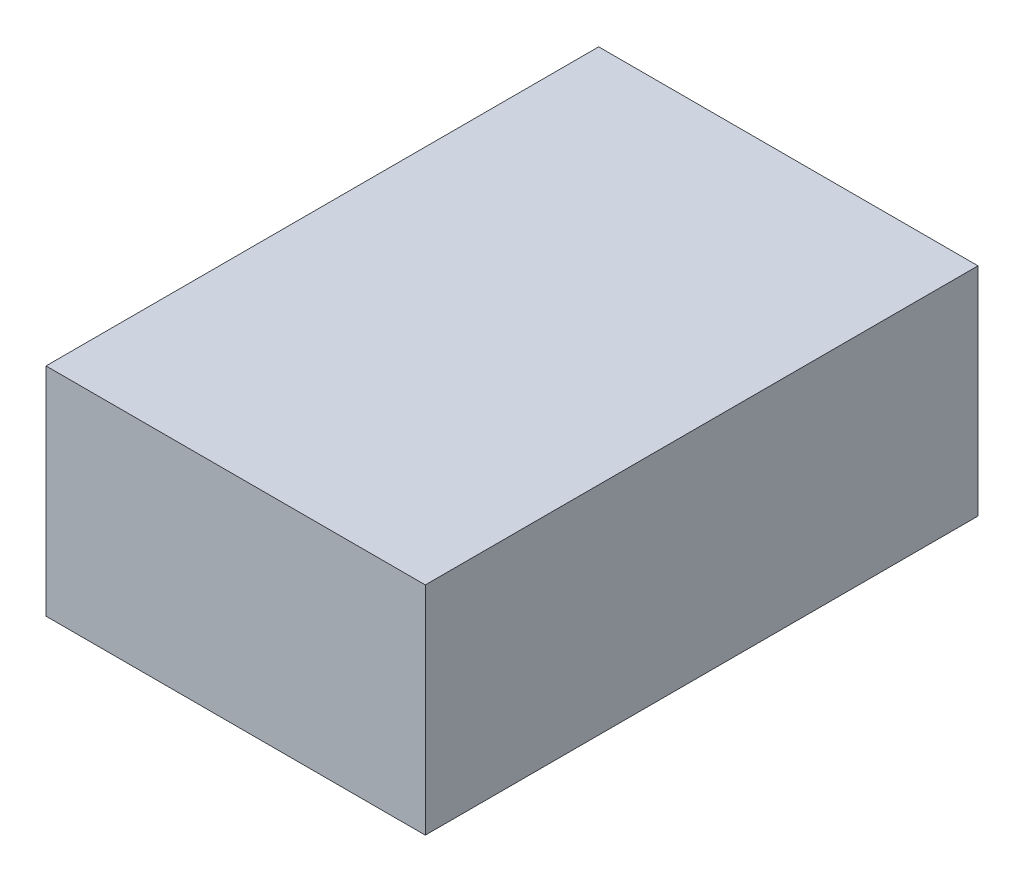
from build123d import *

# Parameters (mm, degrees)
SKETCH1_W           = 0.35
SKETCH1_H           = 0.51
BOSS_EXTRUDE1_DEPTH = 0.2


with BuildPart() as part:
    # Sketch1 → Boss-Extrude1 (new body)
    with BuildSketch(Plane(origin=(0, 0, 0), x_dir=(1, 0, 0), z_dir=(0, 1, 0))):
        Rectangle(SKETCH1_W, SKETCH1_H)
    extrude(amount=BOSS_EXTRUDE1_DEPTH)


solid = part.part
